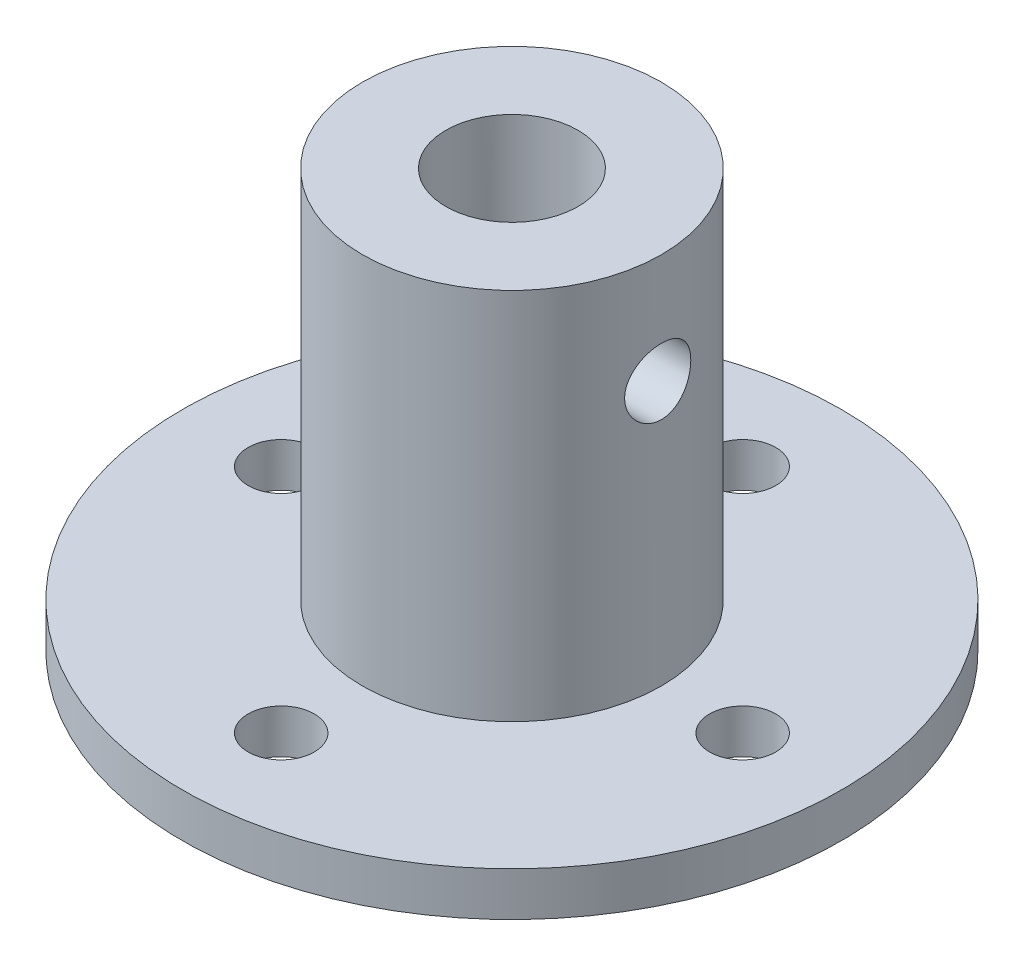
from build123d import *

# Parameters (mm, degrees)
SKETCH1_5_R             = 1.1938
CUT_EXTRUDE1_DEPTH      = 12.8999
CUT_EXTRUDE1_DEPTH_BACK = 12.8999
SKETCH2_R               = 1.1938
CUT_EXTRUDE2_DEPTH      = 17.6624001


with BuildPart() as part:
    # Sketch1 → Revolve1 (revolve)
    with BuildSketch(Plane(origin=(0, 0, 0), x_dir=(0, 0, -1), z_dir=(1, 0, 0))):
        Polygon((3.9243, 0), (2.3876, 0), (2.3876, 16.6624), (5.3975, 16.6624), (5.3975, 3.175), (11.8999, 3.175), (11.8999, 1.5875), (3.9243, 1.5875), align=None)
    revolve(axis=Axis((0, 0, 0), (0, 1, 0)))

    # Sketch1_5 → Cut-Extrude1 (cut, two sides)
    with BuildSketch(Plane(origin=(0, 0, 0), x_dir=(0, 0, -1), z_dir=(1, 0, 0))) as cut_extrude1_sk:
        with Locations((0, 12.7)):
            Circle(SKETCH1_5_R)
    extrude(amount=CUT_EXTRUDE1_DEPTH, mode=Mode.SUBTRACT)
    extrude(cut_extrude1_sk.sketch, amount=-CUT_EXTRUDE1_DEPTH_BACK, mode=Mode.SUBTRACT)

    # Sketch2 → Cut-Extrude2 (cut, through all)
    with BuildSketch(Plane(origin=(0, 0, 0), x_dir=(1, 0, 0), z_dir=(0, 1, 0))):
        with Locations((-8.3312, 0)):
            Circle(SKETCH2_R)
        with Locations((0, 8.3312)):
            Circle(SKETCH2_R)
        with Locations((0, -8.3312)):
            Circle(SKETCH2_R)
        with Locations((8.3312, 0)):
            Circle(SKETCH2_R)
    extrude(amount=CUT_EXTRUDE2_DEPTH, mode=Mode.SUBTRACT)


solid = part.part
